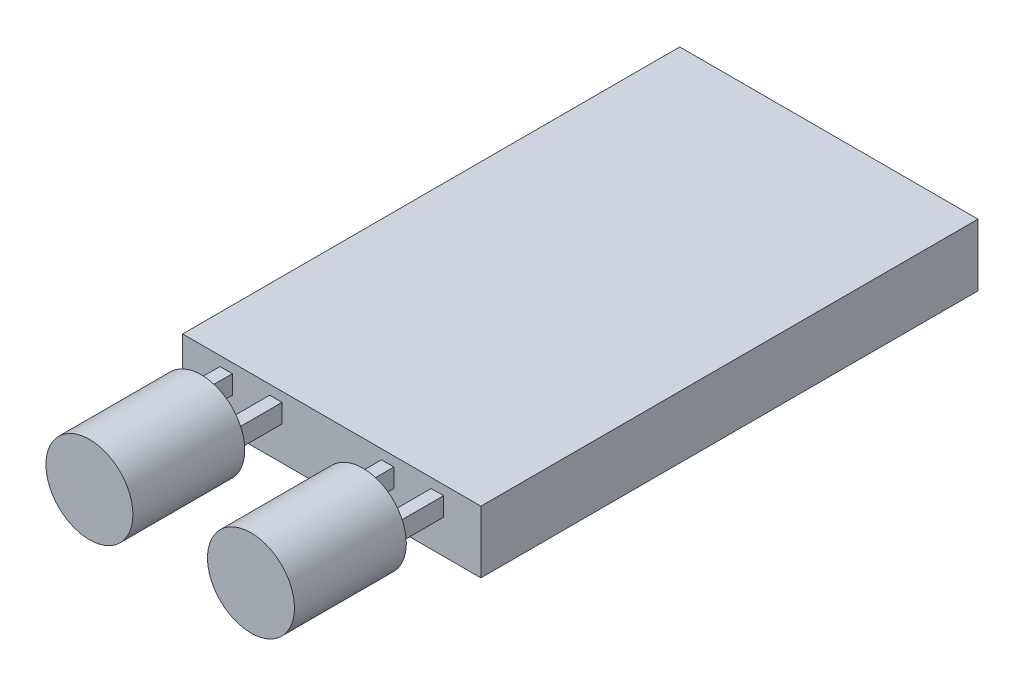
from build123d import *

# Parameters (mm, degrees)
SKETCH1_W           = 24
SKETCH1_H           = 40
BOSS_EXTRUDE1_DEPTH = 5
SKETCH2_W           = 1
SKETCH2_H           = 1.5
BOSS_EXTRUDE5_DEPTH = 44
SKETCH6_R           = 3.5
BOSS_EXTRUDE9_DEPTH = 9


with BuildPart() as part:
    # Sketch1 → Boss-Extrude1 (new body)
    with BuildSketch(Plane(origin=(0, 0, 0), x_dir=(1, 0, 0), z_dir=(0, 1, 0))):
        with Locations((-12, -10.571428571)):
            Rectangle(SKETCH1_W, SKETCH1_H)
    extrude(amount=BOSS_EXTRUDE1_DEPTH)

    # Sketch2 → Boss-Extrude5 (add)
    with BuildSketch(Plane(origin=(0, 0, -9.428571429), x_dir=(-1, 0, 0), z_dir=(0, 0, -1))):
        with Locations((3.5, 3.479518838)):
            Rectangle(SKETCH2_W, SKETCH2_H)
        with Locations((7.5, 3.479518838)):
            Rectangle(SKETCH2_W, SKETCH2_H)
        with Locations((16.5, 3.479518838)):
            Rectangle(SKETCH2_W, SKETCH2_H)
        with Locations((20.5, 3.479518838)):
            Rectangle(SKETCH2_W, SKETCH2_H)
    extrude(amount=-BOSS_EXTRUDE5_DEPTH)

    # Sketch6 → Boss-Extrude9 (add)
    with BuildSketch(Plane.XY.offset(34.571428571)):
        with Locations((-18.5, 3.40608753)):
            Circle(SKETCH6_R)
        with Locations((-5.5, 3.4)):
            Circle(SKETCH6_R)
    extrude(amount=BOSS_EXTRUDE9_DEPTH)


solid = part.part
